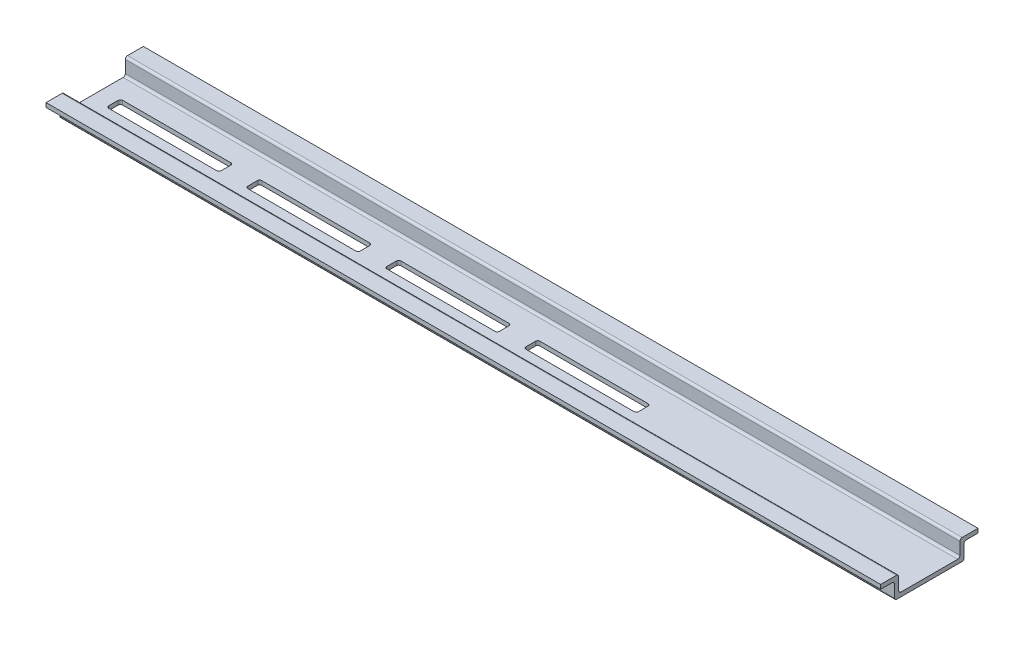
from build123d import *

# Parameters (mm, degrees)
EXTRUDE_1_DEPTH     = 300
CUT_EXTRUDE_1_DEPTH = 10


with BuildPart() as part:
    # Эскиз1 → Бобышка-Вытянуть1 (new body)
    with BuildSketch(Plane(origin=(0, 0, 0), x_dir=(0, 0, -1), z_dir=(1, 0, 0))):
        with BuildLine():
            Line((0, 7.524096324), (0, 6))
            Line((0, 6), (4.2, 6))
            ThreePointArc((4.2, 6), (4.765685425, 5.765685425), (5, 5.2))
            Line((5, 5.2), (5, 0.8))
            ThreePointArc((5, 0.8), (5.234314575, 0.234314575), (5.8, 0))
            Line((5.8, 0), (29.2, 0))
            ThreePointArc((29.2, 0), (29.765685425, 0.234314575), (30, 0.8))
            Line((30, 0.8), (30, 5.2))
            ThreePointArc((30, 5.2), (30.234314575, 5.765685425), (30.8, 6))
            Line((30.8, 6), (35, 6))
            Line((35, 6), (35, 7.5))
            Line((35, 7.5), (29.3, 7.5))
            ThreePointArc((29.3, 7.5), (28.734314575, 7.265685425), (28.5, 6.7))
            Line((28.5, 6.7), (28.5, 2.3))
            ThreePointArc((28.5, 2.3), (28.265685425, 1.734314575), (27.7, 1.5))
            Line((27.7, 1.5), (7.3, 1.5))
            ThreePointArc((7.3, 1.5), (6.734314575, 1.734314575), (6.5, 2.3))
            Line((6.5, 2.3), (6.5, 6.724096324))
            ThreePointArc((6.5, 6.724096324), (6.265685425, 7.289781749), (5.7, 7.524096324))
            Line((5.7, 7.524096324), (0, 7.524096324))
        make_face()
    extrude(amount=EXTRUDE_1_DEPTH)

    # Эскиз2 → Вырез-Вытянуть1 (cut)
    with BuildSketch(Plane(origin=(0, 1.5, 0), x_dir=(1, 0, 0), z_dir=(0, 1, 0))):
        with BuildLine():
            Line((57.050825201, 20.5), (95.873378283, 20.5))
            ThreePointArc((95.873378283, 20.5), (96.439063708, 20.265685425), (96.673378283, 19.7))
            Line((96.673378283, 19.7), (96.673378283, 16.3))
            ThreePointArc((96.673378283, 16.3), (96.439063708, 15.734314575), (95.873378283, 15.5))
            Line((95.873378283, 15.5), (57.050825201, 15.5))
            ThreePointArc((57.050825201, 15.5), (56.485139776, 15.734314575), (56.250825201, 16.3))
            Line((56.250825201, 16.3), (56.250825201, 19.7))
            ThreePointArc((56.250825201, 19.7), (56.485139776, 20.265685425), (57.050825201, 20.5))
        make_face()
        with BuildLine():
            Line((7.050825201, 20.5), (45.873378283, 20.5))
            ThreePointArc((45.873378283, 20.5), (46.439063708, 20.265685425), (46.673378283, 19.7))
            Line((46.673378283, 19.7), (46.673378283, 16.3))
            ThreePointArc((46.673378283, 16.3), (46.439063708, 15.734314575), (45.873378283, 15.5))
            Line((45.873378283, 15.5), (7.050825201, 15.5))
            ThreePointArc((7.050825201, 15.5), (6.485139776, 15.734314575), (6.250825201, 16.3))
            Line((6.250825201, 16.3), (6.250825201, 19.7))
            ThreePointArc((6.250825201, 19.7), (6.485139776, 20.265685425), (7.050825201, 20.5))
        make_face()
        with BuildLine():
            Line((107.050825201, 20.5), (145.873378283, 20.5))
            ThreePointArc((145.873378283, 20.5), (146.439063708, 20.265685425), (146.673378283, 19.7))
            Line((146.673378283, 19.7), (146.673378283, 16.3))
            ThreePointArc((146.673378283, 16.3), (146.439063708, 15.734314575), (145.873378283, 15.5))
            Line((145.873378283, 15.5), (107.050825201, 15.5))
            ThreePointArc((107.050825201, 15.5), (106.485139776, 15.734314575), (106.250825201, 16.3))
            Line((106.250825201, 16.3), (106.250825201, 19.7))
            ThreePointArc((106.250825201, 19.7), (106.485139776, 20.265685425), (107.050825201, 20.5))
        make_face()
        with BuildLine():
            Line((157.050825201, 20.5), (195.873378283, 20.5))
            ThreePointArc((195.873378283, 20.5), (196.439063708, 20.265685425), (196.673378283, 19.7))
            Line((196.673378283, 19.7), (196.673378283, 16.3))
            ThreePointArc((196.673378283, 16.3), (196.439063708, 15.734314575), (195.873378283, 15.5))
            Line((195.873378283, 15.5), (157.050825201, 15.5))
            ThreePointArc((157.050825201, 15.5), (156.485139776, 15.734314575), (156.250825201, 16.3))
            Line((156.250825201, 16.3), (156.250825201, 19.7))
            ThreePointArc((156.250825201, 19.7), (156.485139776, 20.265685425), (157.050825201, 20.5))
        make_face()
    extrude(amount=-CUT_EXTRUDE_1_DEPTH, mode=Mode.SUBTRACT)


solid = part.part
